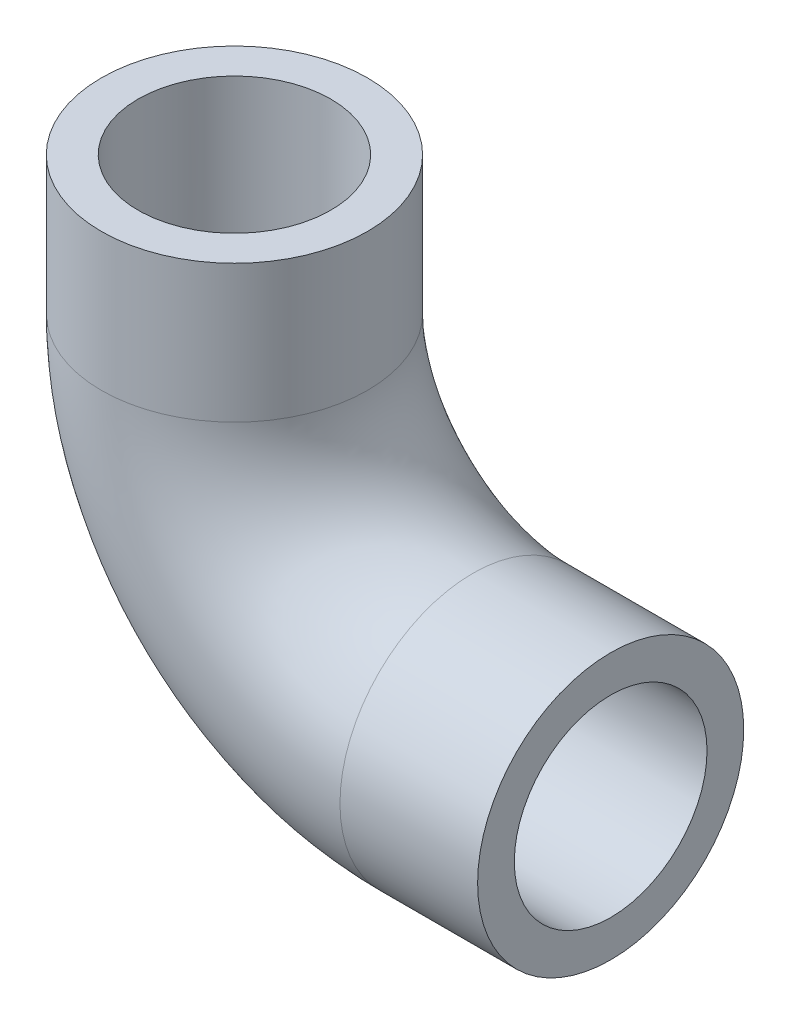
from build123d import *

# Parameters (mm, degrees)
SWEEP_THIN1_PROFILE_R   = 145
SWEEP_THIN1_PROFILE_R_2 = 105


with BuildPart() as part:
    # Sweep-Thin1: sweep along a path in Sketch1
    with BuildLine(Plane.XY) as sweep_thin1_path:
        Line((0, 0), (-150, 0))
        ThreePointArc((-150, 0), (-333.847763109, 76.152236891), (-410, 260))
        Line((-410, 260), (-410, 410))
    # Sweep-Thin1 profile (on start of the path) → Sweep-Thin1 (sweep)
    with BuildSketch(Plane(origin=(0, 0, 0), x_dir=(0, -1, 0), z_dir=(-1, 0, 0))):
        Circle(SWEEP_THIN1_PROFILE_R)
        Circle(SWEEP_THIN1_PROFILE_R_2, mode=Mode.SUBTRACT)
    sweep(path=sweep_thin1_path.line)


solid = part.part
